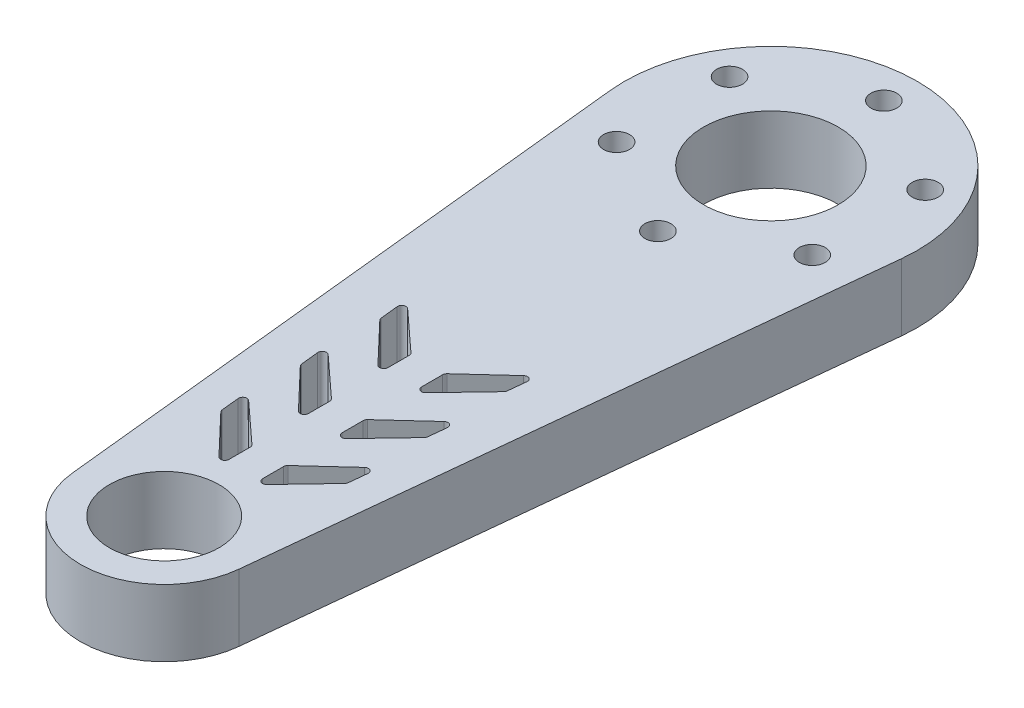
from build123d import *

# Parameters (mm, degrees)
EXTRUDE_1_DEPTH                = 8
CUT_EXTRUDE_1_DEPTH            = 9
CUT_EXTRUDE_2_DEPTH            = 9
CUT_EXTRUDE_3_DEPTH            = 9
CUT_EXTRUDE_4_DEPTH            = 9
CUT_EXTRUDE_5_DEPTH            = 9
CUT_EXTRUDE_6_DEPTH            = 9
HOLE_WIZARD_16_0_16_1_D        = 16.1
HOLE_WIZARD_16_0_16_1_DEPTH    = 8
HOLE_WIZARD_13_0_13_1_D        = 13.1
HOLE_WIZARD_13_0_13_1_DEPTH    = 8
HOLE_WIZARD_M2_5_1_D           = 3.1
HOLE_WIZARD_M2_5_1_DEPTH       = 8
HOLE_WIZARD_M2_5_1_CBORE_D     = 5.6
HOLE_WIZARD_M2_5_1_CBORE_DEPTH = 3
FILLET_1_R                     = 0.5


with BuildPart() as part:
    # 草图1 → 凸台-拉伸1 (new body)
    with BuildSketch(Plane(origin=(0, 4, 0), x_dir=(1, 0, 0), z_dir=(0, 1, 0))):
        with BuildLine():
            Line((-17.406109606, -1.810344828), (-9.946348346, -73.534482759))
            ThreePointArc((-9.946348346, -73.534482759), (0, -82.5), (9.946348346, -73.534482759))
            Line((9.946348346, -73.534482759), (17.406109606, -1.810344828))
            ThreePointArc((17.406109606, -1.810344828), (0, 17.5), (-17.406109606, -1.810344828))
        make_face()
    extrude(amount=-EXTRUDE_1_DEPTH)

    # 草图2 → 切除-拉伸1 (cut, through all)
    with BuildSketch(Plane(origin=(0, 4, 0), x_dir=(-1, 0, 0), z_dir=(0, 1, 0))):
        with BuildLine():
            Line((2, 43.750482659), (2, 41))
            Line((2, 41), (6.923179382, 36.483241979))
            ThreePointArc((6.923179382, 36.483241979), (7.485869271, 36.40499598), (7.758515386, 36.903399876))
            Line((7.758515386, 36.903399876), (7.518784371, 39.208366459))
            Line((7.518784371, 39.208366459), (2.861977096, 44.095406683))
            ThreePointArc((2.861977096, 44.095406683), (2.314242831, 44.214696268), (2, 43.750482659))
        make_face()
    extrude(amount=-CUT_EXTRUDE_1_DEPTH, mode=Mode.SUBTRACT)

    # 草图3 → 切除-拉伸2 (cut, through all)
    with BuildSketch(Plane(origin=(0, 4, 0), x_dir=(-1, 0, 0), z_dir=(0, 1, 0))):
        with BuildLine():
            Line((-6.923179382, 36.483241979), (-2, 41))
            Line((-2, 41), (-2, 43.750482659))
            ThreePointArc((-2, 43.750482659), (-2.314242831, 44.214696268), (-2.861977096, 44.095406683))
            Line((-2.861977096, 44.095406683), (-7.518784371, 39.208366459))
            Line((-7.518784371, 39.208366459), (-7.758515386, 36.903399876))
            ThreePointArc((-7.758515386, 36.903399876), (-7.485869271, 36.40499598), (-6.923179382, 36.483241979))
        make_face()
    extrude(amount=-CUT_EXTRUDE_2_DEPTH, mode=Mode.SUBTRACT)

    # 草图4 → 切除-拉伸3 (cut, through all)
    with BuildSketch(Plane(origin=(0, 4, 0), x_dir=(-1, 0, 0), z_dir=(0, 1, 0))):
        with BuildLine():
            Line((2, 53.250482659), (2, 50.5))
            Line((2, 50.5), (6.923179382, 45.983241979))
            ThreePointArc((6.923179382, 45.983241979), (7.485869271, 45.90499598), (7.758515386, 46.403399876))
            Line((7.758515386, 46.403399876), (7.518784371, 48.708366459))
            Line((7.518784371, 48.708366459), (2.861977096, 53.595406683))
            ThreePointArc((2.861977096, 53.595406683), (2.314242831, 53.714696268), (2, 53.250482659))
        make_face()
    extrude(amount=-CUT_EXTRUDE_3_DEPTH, mode=Mode.SUBTRACT)

    # 草图5 → 切除-拉伸4 (cut, through all)
    with BuildSketch(Plane(origin=(0, 4, 0), x_dir=(-1, 0, 0), z_dir=(0, 1, 0))):
        with BuildLine():
            Line((-6.923179382, 45.983241979), (-2, 50.5))
            Line((-2, 50.5), (-2, 53.250482659))
            ThreePointArc((-2, 53.250482659), (-2.314242831, 53.714696268), (-2.861977096, 53.595406683))
            Line((-2.861977096, 53.595406683), (-7.518784371, 48.708366459))
            Line((-7.518784371, 48.708366459), (-7.758515386, 46.403399876))
            ThreePointArc((-7.758515386, 46.403399876), (-7.485869271, 45.90499598), (-6.923179382, 45.983241979))
        make_face()
    extrude(amount=-CUT_EXTRUDE_4_DEPTH, mode=Mode.SUBTRACT)

    # 草图6 → 切除-拉伸5 (cut, through all)
    with BuildSketch(Plane(origin=(0, 4, 0), x_dir=(-1, 0, 0), z_dir=(0, 1, 0))):
        with BuildLine():
            Line((2, 62.750482659), (2, 60))
            Line((2, 60), (6.923179382, 55.483241979))
            ThreePointArc((6.923179382, 55.483241979), (7.485869271, 55.40499598), (7.758515386, 55.903399876))
            Line((7.758515386, 55.903399876), (7.518784371, 58.208366459))
            Line((7.518784371, 58.208366459), (2.861977096, 63.095406683))
            ThreePointArc((2.861977096, 63.095406683), (2.314242831, 63.214696268), (2, 62.750482659))
        make_face()
    extrude(amount=-CUT_EXTRUDE_5_DEPTH, mode=Mode.SUBTRACT)

    # 草图7 → 切除-拉伸6 (cut, through all)
    with BuildSketch(Plane.XZ.offset(4)):
        with BuildLine():
            Line((2, 62.750482659), (2, 60))
            Line((2, 60), (6.923179382, 55.483241979))
            ThreePointArc((6.923179382, 55.483241979), (7.485869271, 55.40499598), (7.758515386, 55.903399876))
            Line((7.758515386, 55.903399876), (7.518784371, 58.208366459))
            Line((7.518784371, 58.208366459), (2.861977096, 63.095406683))
            ThreePointArc((2.861977096, 63.095406683), (2.314242831, 63.214696268), (2, 62.750482659))
        make_face()
    extrude(amount=-CUT_EXTRUDE_6_DEPTH, mode=Mode.SUBTRACT)

    # Ø16.0 (16) 直径孔1
    with Locations(Plane(origin=(0, -4, 0), x_dir=(-1, 0, 0), z_dir=(0, -1, 0))):
        with Locations((0, 0)):
            Hole(HOLE_WIZARD_16_0_16_1_D / 2, depth=HOLE_WIZARD_16_0_16_1_DEPTH)

    # Ø13.0 (13) 直径孔1
    with Locations(Plane(origin=(0, 4, 0), x_dir=(1, 0, 0), z_dir=(0, 1, 0))):
        with Locations((0, -72.5)):
            Hole(HOLE_WIZARD_13_0_13_1_D / 2, depth=HOLE_WIZARD_13_0_13_1_DEPTH)

    # M2.5 六角头机械螺钉的柱形沉头孔1
    with Locations(Plane(origin=(0, -4, 0), x_dir=(-1, 0, 0), z_dir=(0, -1, 0))):
        with Locations((11.691342951, -6.75), (11.691342951, 6.75), (0, 13.5), (-11.691342951, 6.75), (-11.691342951, -6.75), (0, -13.5)):
            CounterBoreHole(HOLE_WIZARD_M2_5_1_D / 2, HOLE_WIZARD_M2_5_1_CBORE_D / 2, HOLE_WIZARD_M2_5_1_CBORE_DEPTH, depth=HOLE_WIZARD_M2_5_1_DEPTH)

    # 圆角1
    fillet_1_edges = [part.edges().sort_by_distance(p)[0] for p in [
        (-7.518784371, 0, 58.208366459),
        (-2, 0, 60),
        (7.518784371, 0, 58.208366459),
        (2, 0, 60),
        (-7.518784371, 0, 39.208366459),
        (-2, 0, 41),
        (7.518784371, 0, 39.208366459),
        (2, 0, 41),
        (-7.518784371, 0, 48.708366459),
        (-2, 0, 50.5),
        (7.518784371, 0, 48.708366459),
        (2, 0, 50.5),
    ]]
    fillet(fillet_1_edges, radius=FILLET_1_R)


solid = part.part
